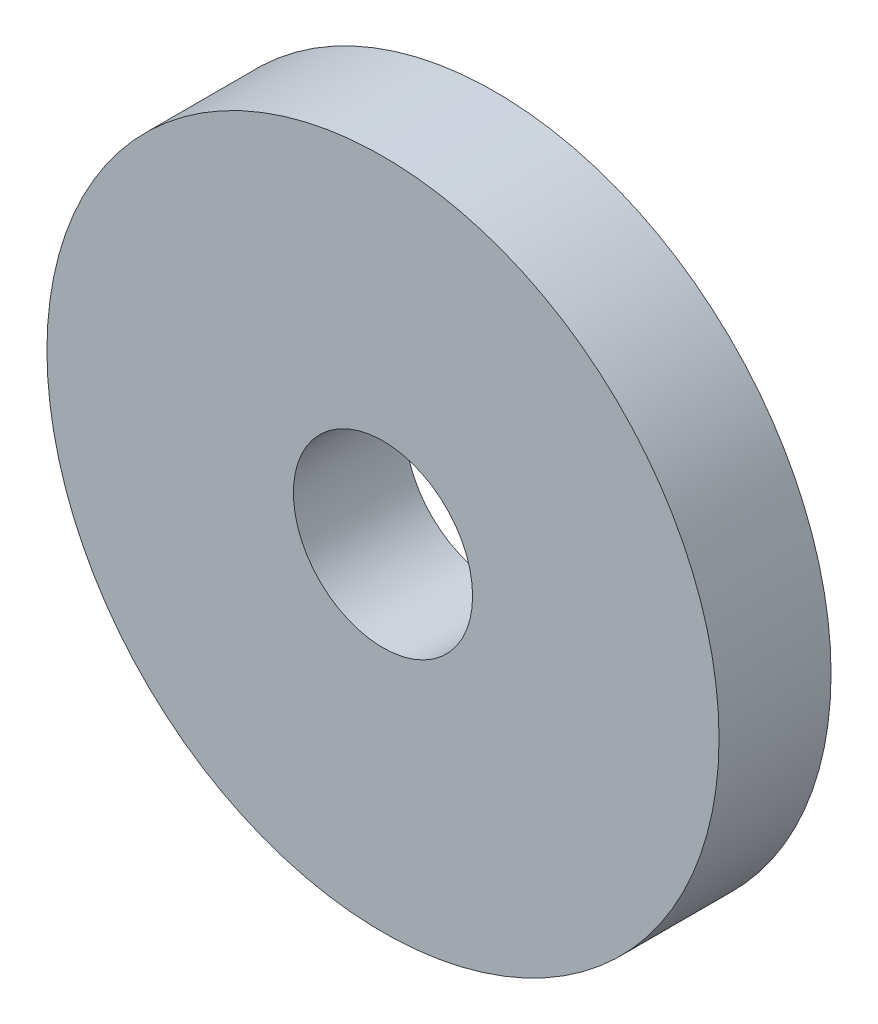
from build123d import *

# Parameters (mm, degrees)
CROQUIS1_R                 = 6
CROQUIS1_R_2               = 1.6
ARANDELA_ESPACIADORA_DEPTH = 2


with BuildPart() as part:
    # Croquis1 → Arandela espaciadora (new body)
    with BuildSketch(Plane.XY):
        Circle(CROQUIS1_R)
        Circle(CROQUIS1_R_2, mode=Mode.SUBTRACT)
    extrude(amount=ARANDELA_ESPACIADORA_DEPTH)


solid = part.part
